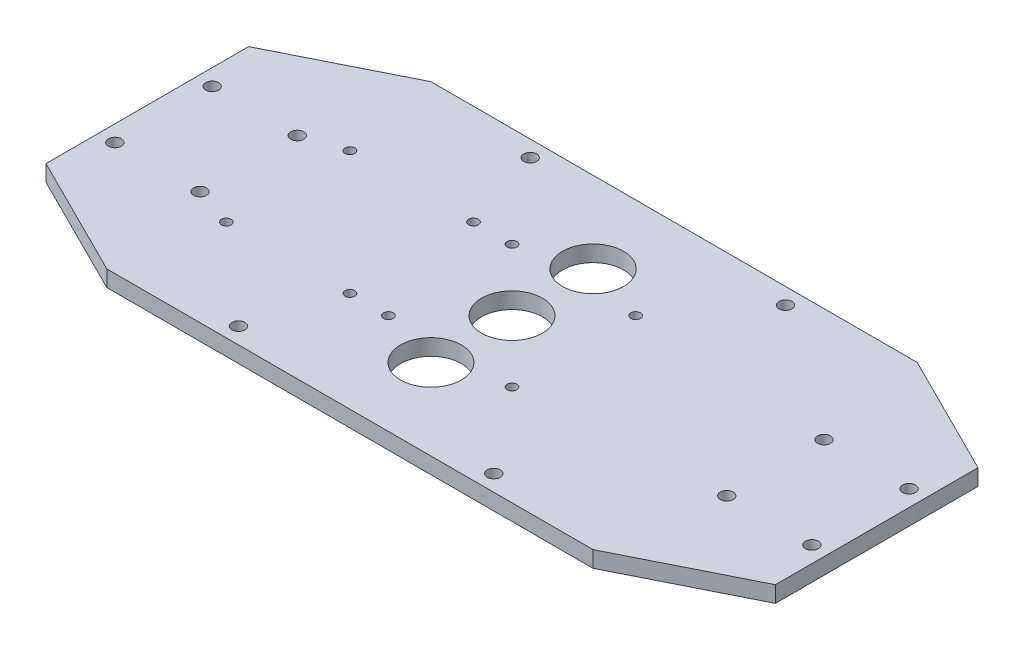
from build123d import *

# Parameters (mm, degrees)
ESQUISSE1_W             = 180
ESQUISSE1_H             = 80
BOSS_EXTRU_1_DEPTH      = 4
ENL_V_MAT_EXTRU_1_DEPTH = 4
D_GAGEMENT_M22_D        = 2.4
D_GAGEMENT_M23_D        = 2.4
D_GAGEMENT_M31_D        = 3.2
D_GAGEMENT_M31_DEPTH    = 4
ESQUISSE17_R            = 7.534005168
ESQUISSE17_R_2          = 7.5
ENL_V_MAT_EXTRU_2_DEPTH = 10


with BuildPart() as part:
    # Esquisse1 → Boss.-Extru.1 (new body)
    with BuildSketch(Plane(origin=(0, 0, 0), x_dir=(1, 0, 0), z_dir=(0, 1, 0))):
        with Locations((90, 40)):
            Rectangle(ESQUISSE1_W, ESQUISSE1_H)
    extrude(amount=BOSS_EXTRU_1_DEPTH)

    # Esquisse2 → Enlèv. mat.-Extru.1 (cut)
    with BuildSketch(Plane(origin=(0, 4, 0), x_dir=(1, 0, 0), z_dir=(0, 1, 0))):
        Polygon((0, 15), (30, 0), (0, 0), align=None)
        Polygon((30, 80), (0, 65), (0, 80), align=None)
        Polygon((150, 80), (180, 80), (180, 65), align=None)
        Polygon((180, 15), (150, 0), (180, 0), align=None)
    extrude(amount=-ENL_V_MAT_EXTRU_1_DEPTH, mode=Mode.SUBTRACT)

    # Dégagement M22 (through all)
    with Locations(Plane(origin=(0, 4, 0), x_dir=(1, 0, 0), z_dir=(0, 1, 0))):
        with Locations((74.75, 55.25), (105.25, 55.25), (105.25, 24.75), (74.75, 24.75)):
            Hole(D_GAGEMENT_M22_D / 2)

    # Dégagement M23 (through all)
    with Locations(Plane(origin=(0, 4, 0), x_dir=(1, 0, 0), z_dir=(0, 1, 0))):
        with Locations((34.75, 24.75), (65.25, 24.75), (65.25, 55.25), (34.75, 55.25)):
            Hole(D_GAGEMENT_M23_D / 2)

    # Dégagement M31
    with Locations(Plane(origin=(0, 4, 0), x_dir=(1, 0, 0), z_dir=(0, 1, 0))):
        with Locations((4, 52), (4, 28), (25, 28), (25, 52), (58.5, 76), (58.5, 4), (121.5, 4), (121.5, 76), (155, 52), (176, 52), (176, 28), (155, 28)):
            Hole(D_GAGEMENT_M31_D / 2, depth=D_GAGEMENT_M31_DEPTH)

    # Esquisse17 → Enlèv. mat.-Extru.2 (cut)
    with BuildSketch(Plane(origin=(0, 4, 0), x_dir=(1, 0, 0), z_dir=(0, 1, 0))):
        with Locations((90, 60)):
            Circle(ESQUISSE17_R)
        with Locations((90, 40)):
            Circle(ESQUISSE17_R_2)
        with Locations((90, 20)):
            Circle(ESQUISSE17_R_2)
    extrude(amount=-ENL_V_MAT_EXTRU_2_DEPTH, mode=Mode.SUBTRACT)


solid = part.part
